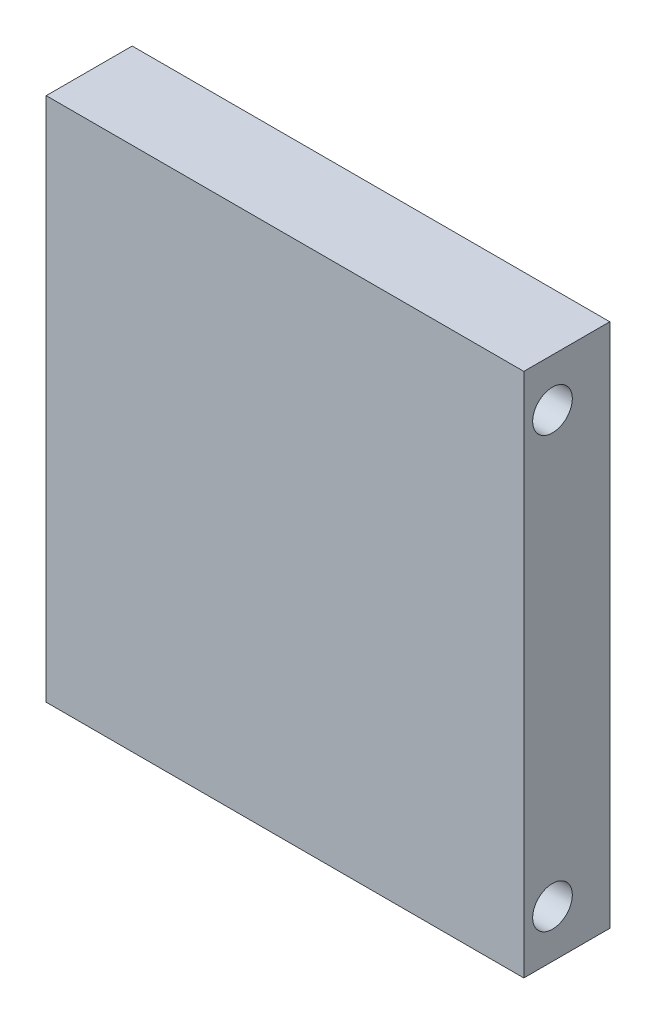
from build123d import *

# Parameters (mm, degrees)
ESBO_O1_W                = 100
ESBO_O1_H                = 110
RESSALTO_EXTRUS_O1_DEPTH = 18
ESBO_O2_W                = 18
ESBO_O2_H                = 18
RESSALTO_EXTRUS_O2_DEPTH = 10
ESBO_O3_R                = 4.15
CORTE_EXTRUS_O1_DEPTH    = 101


with BuildPart() as part:
    # Esboço1 → Ressalto-extrusão1 (new body)
    with BuildSketch(Plane.XY):
        Rectangle(ESBO_O1_W, ESBO_O1_H)
    extrude(amount=RESSALTO_EXTRUS_O1_DEPTH)

    # Esboço2 → Ressalto-extrusão2 (add)
    with BuildSketch(Plane(origin=(0, 0, 0), x_dir=(-1, 0, 0), z_dir=(0, 0, -1))):
        with Locations((-25, -25)):
            Rectangle(ESBO_O2_W, ESBO_O2_H)
        with Locations((25, -25)):
            Rectangle(ESBO_O2_W, ESBO_O2_H)
        with Locations((-25, 25)):
            Rectangle(ESBO_O2_W, ESBO_O2_H)
        with Locations((25, 25)):
            Rectangle(ESBO_O2_W, ESBO_O2_H)
    extrude(amount=RESSALTO_EXTRUS_O2_DEPTH)

    # Esboço3 → Corte-extrusão1 (cut, through all)
    with BuildSketch(Plane.ZY.offset(50)):
        with Locations((12, 45)):
            Circle(ESBO_O3_R)
        with Locations((12, -45)):
            Circle(ESBO_O3_R)
    extrude(amount=-CORTE_EXTRUS_O1_DEPTH, mode=Mode.SUBTRACT)


solid = part.part
